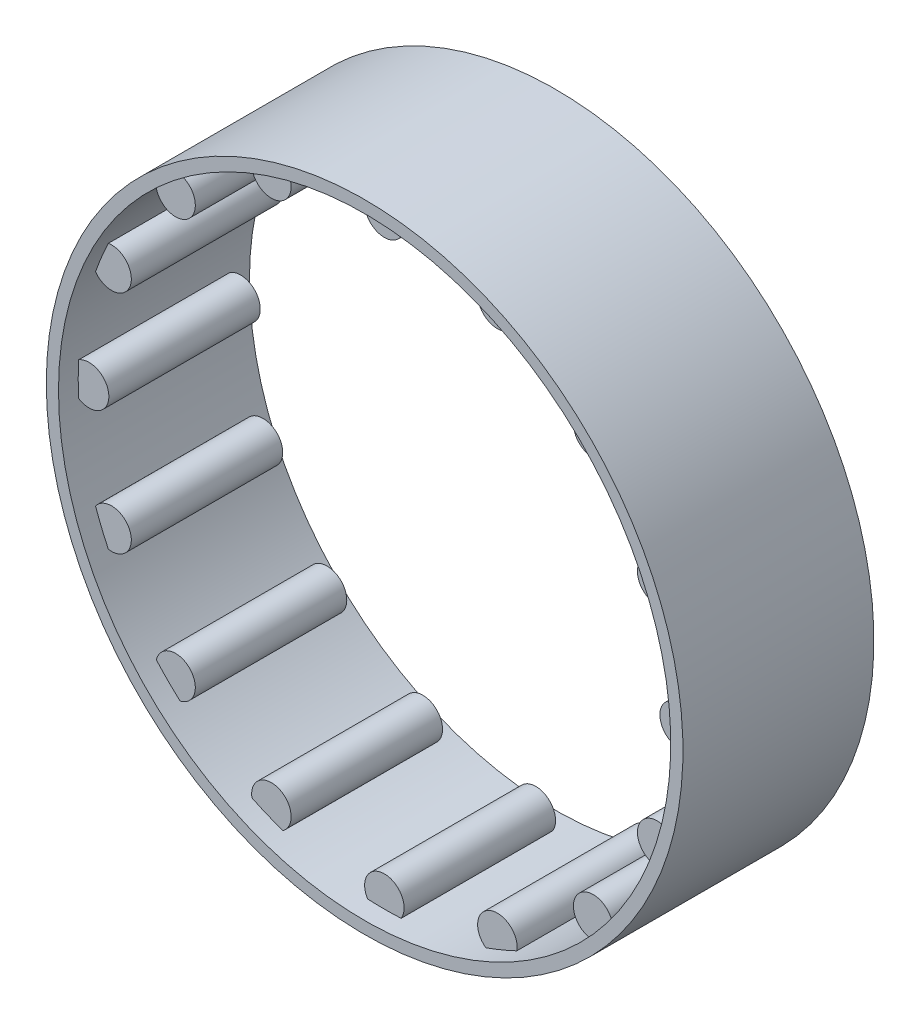
from build123d import *

# Parameters (mm, degrees)
SKETCH1_R              = 3
BOSS_EXTRUDE2_DEPTH    = 29
BOSS_EXTRUDE2_2_DEPTH  = 29
BOSS_EXTRUDE2_3_DEPTH  = 29
BOSS_EXTRUDE2_4_DEPTH  = 29
BOSS_EXTRUDE2_5_DEPTH  = 29
BOSS_EXTRUDE2_6_DEPTH  = 29
BOSS_EXTRUDE2_7_DEPTH  = 29
BOSS_EXTRUDE2_8_DEPTH  = 29
BOSS_EXTRUDE2_9_DEPTH  = 29
BOSS_EXTRUDE2_10_DEPTH = 29
BOSS_EXTRUDE2_11_DEPTH = 29
BOSS_EXTRUDE2_12_DEPTH = 29
BOSS_EXTRUDE2_13_DEPTH = 29
BOSS_EXTRUDE2_14_DEPTH = 29
BOSS_EXTRUDE2_15_DEPTH = 29
BOSS_EXTRUDE2_16_DEPTH = 29
SKETCH2_R              = 47.85
SKETCH2_R_2            = 46.5
BOSS_EXTRUDE4_DEPTH    = 29
SKETCH3_R              = 46.5
CUT_EXTRUDE1_DEPTH     = 3
SKETCH4_R              = 46.5
CUT_EXTRUDE2_DEPTH     = 3
SKETCH5_R              = 48.35
SKETCH5_R_2            = 47.85
BOSS_EXTRUDE6_DEPTH    = 29


with BuildPart() as part:
    # Sketch1 → Boss-Extrude2 (new body)
    with BuildSketch(Plane.XY):
        with Locations((-41.435997033, 17.163351942)):
            Circle(SKETCH1_R)
    extrude(amount=BOSS_EXTRUDE2_DEPTH)


with BuildPart() as body_2:
    # Sketch1 → Boss-Extrude2 2 (new body)
    with BuildSketch(Plane.XY):
        with Locations((-31.713739136, 31.713739136)):
            Circle(SKETCH1_R)
    extrude(amount=BOSS_EXTRUDE2_2_DEPTH)


with BuildPart() as body_3:
    # Sketch1 → Boss-Extrude2 3 (new body)
    with BuildSketch(Plane.XY):
        with Locations((-17.163351942, 41.435997033)):
            Circle(SKETCH1_R)
    extrude(amount=BOSS_EXTRUDE2_3_DEPTH)


with BuildPart() as body_4:
    # Sketch1 → Boss-Extrude2 4 (new body)
    with BuildSketch(Plane.XY):
        with Locations((0, 44.85)):
            Circle(SKETCH1_R)
    extrude(amount=BOSS_EXTRUDE2_4_DEPTH)


with BuildPart() as body_5:
    # Sketch1 → Boss-Extrude2 5 (new body)
    with BuildSketch(Plane.XY):
        with Locations((17.163351942, 41.435997033)):
            Circle(SKETCH1_R)
    extrude(amount=BOSS_EXTRUDE2_5_DEPTH)


with BuildPart() as body_6:
    # Sketch1 → Boss-Extrude2 6 (new body)
    with BuildSketch(Plane.XY):
        with Locations((31.713739136, 31.713739136)):
            Circle(SKETCH1_R)
    extrude(amount=BOSS_EXTRUDE2_6_DEPTH)


with BuildPart() as body_7:
    # Sketch1 → Boss-Extrude2 7 (new body)
    with BuildSketch(Plane.XY):
        with Locations((41.435997033, 17.163351942)):
            Circle(SKETCH1_R)
    extrude(amount=BOSS_EXTRUDE2_7_DEPTH)


with BuildPart() as body_8:
    # Sketch1 → Boss-Extrude2 8 (new body)
    with BuildSketch(Plane.XY):
        with Locations((44.85, 0)):
            Circle(SKETCH1_R)
    extrude(amount=BOSS_EXTRUDE2_8_DEPTH)


with BuildPart() as body_9:
    # Sketch1 → Boss-Extrude2 9 (new body)
    with BuildSketch(Plane.XY):
        with Locations((41.435997033, -17.163351942)):
            Circle(SKETCH1_R)
    extrude(amount=BOSS_EXTRUDE2_9_DEPTH)


with BuildPart() as body_10:
    # Sketch1 → Boss-Extrude2 10 (new body)
    with BuildSketch(Plane.XY):
        with Locations((17.163351942, -41.435997033)):
            Circle(SKETCH1_R)
    extrude(amount=BOSS_EXTRUDE2_10_DEPTH)


with BuildPart() as body_11:
    # Sketch1 → Boss-Extrude2 11 (new body)
    with BuildSketch(Plane.XY):
        with Locations((0, -44.85)):
            Circle(SKETCH1_R)
    extrude(amount=BOSS_EXTRUDE2_11_DEPTH)


with BuildPart() as body_12:
    # Sketch1 → Boss-Extrude2 12 (new body)
    with BuildSketch(Plane.XY):
        with Locations((-17.163351942, -41.435997033)):
            Circle(SKETCH1_R)
    extrude(amount=BOSS_EXTRUDE2_12_DEPTH)


with BuildPart() as body_13:
    # Sketch1 → Boss-Extrude2 13 (new body)
    with BuildSketch(Plane.XY):
        with Locations((-41.435997033, -17.163351942)):
            Circle(SKETCH1_R)
    extrude(amount=BOSS_EXTRUDE2_13_DEPTH)


with BuildPart() as body_14:
    # Sketch1 → Boss-Extrude2 14 (new body)
    with BuildSketch(Plane.XY):
        with Locations((-31.713739136, -31.713739136)):
            Circle(SKETCH1_R)
    extrude(amount=BOSS_EXTRUDE2_14_DEPTH)


with BuildPart() as body_15:
    # Sketch1 → Boss-Extrude2 15 (new body)
    with BuildSketch(Plane.XY):
        with Locations((-44.85, 0)):
            Circle(SKETCH1_R)
    extrude(amount=BOSS_EXTRUDE2_15_DEPTH)


with BuildPart() as body_16:
    # Sketch1 → Boss-Extrude2 16 (new body)
    with BuildSketch(Plane.XY):
        with Locations((31.713739136, -31.713739136)):
            Circle(SKETCH1_R)
    extrude(amount=BOSS_EXTRUDE2_16_DEPTH)


with BuildPart() as body_17:
    # Sketch2 → Boss-Extrude4 (new body)
    with BuildSketch(Plane(origin=(0, 0, 0), x_dir=(-1, 0, 0), z_dir=(0, 0, -1))):
        Circle(SKETCH2_R)
        Circle(SKETCH2_R_2, mode=Mode.SUBTRACT)
    extrude(amount=-BOSS_EXTRUDE4_DEPTH)


with BuildPart() as cut_extrude1_tool:
    # Sketch3 → Cut-Extrude1 (new body)
    with BuildSketch(Plane(origin=(0, 0, 0), x_dir=(-1, 0, 0), z_dir=(0, 0, -1))):
        Circle(SKETCH3_R)
    extrude(amount=-CUT_EXTRUDE1_DEPTH)


with BuildPart() as part_1:
    add(part.part)

    # Cut-Extrude1: cut by cut_extrude1_tool
    add(cut_extrude1_tool.part, mode=Mode.SUBTRACT)


with BuildPart() as body_2_1:
    add(body_2.part)

    # Cut-Extrude1: cut by cut_extrude1_tool
    add(cut_extrude1_tool.part, mode=Mode.SUBTRACT)


with BuildPart() as body_3_1:
    add(body_3.part)

    # Cut-Extrude1: cut by cut_extrude1_tool
    add(cut_extrude1_tool.part, mode=Mode.SUBTRACT)


with BuildPart() as body_4_1:
    add(body_4.part)

    # Cut-Extrude1: cut by cut_extrude1_tool
    add(cut_extrude1_tool.part, mode=Mode.SUBTRACT)


with BuildPart() as body_5_1:
    add(body_5.part)

    # Cut-Extrude1: cut by cut_extrude1_tool
    add(cut_extrude1_tool.part, mode=Mode.SUBTRACT)


with BuildPart() as body_6_1:
    add(body_6.part)

    # Cut-Extrude1: cut by cut_extrude1_tool
    add(cut_extrude1_tool.part, mode=Mode.SUBTRACT)


with BuildPart() as body_7_1:
    add(body_7.part)

    # Cut-Extrude1: cut by cut_extrude1_tool
    add(cut_extrude1_tool.part, mode=Mode.SUBTRACT)


with BuildPart() as body_8_1:
    add(body_8.part)

    # Cut-Extrude1: cut by cut_extrude1_tool
    add(cut_extrude1_tool.part, mode=Mode.SUBTRACT)


with BuildPart() as body_9_1:
    add(body_9.part)

    # Cut-Extrude1: cut by cut_extrude1_tool
    add(cut_extrude1_tool.part, mode=Mode.SUBTRACT)


with BuildPart() as body_10_1:
    add(body_10.part)

    # Cut-Extrude1: cut by cut_extrude1_tool
    add(cut_extrude1_tool.part, mode=Mode.SUBTRACT)


with BuildPart() as body_11_1:
    add(body_11.part)

    # Cut-Extrude1: cut by cut_extrude1_tool
    add(cut_extrude1_tool.part, mode=Mode.SUBTRACT)


with BuildPart() as body_12_1:
    add(body_12.part)

    # Cut-Extrude1: cut by cut_extrude1_tool
    add(cut_extrude1_tool.part, mode=Mode.SUBTRACT)


with BuildPart() as body_13_1:
    add(body_13.part)

    # Cut-Extrude1: cut by cut_extrude1_tool
    add(cut_extrude1_tool.part, mode=Mode.SUBTRACT)


with BuildPart() as body_14_1:
    add(body_14.part)

    # Cut-Extrude1: cut by cut_extrude1_tool
    add(cut_extrude1_tool.part, mode=Mode.SUBTRACT)


with BuildPart() as body_15_1:
    add(body_15.part)

    # Cut-Extrude1: cut by cut_extrude1_tool
    add(cut_extrude1_tool.part, mode=Mode.SUBTRACT)


with BuildPart() as body_16_1:
    add(body_16.part)

    # Cut-Extrude1: cut by cut_extrude1_tool
    add(cut_extrude1_tool.part, mode=Mode.SUBTRACT)


with BuildPart() as cut_extrude2_tool:
    # Sketch4 → Cut-Extrude2 (new body)
    with BuildSketch(Plane.XY.offset(29)):
        Circle(SKETCH4_R)
    extrude(amount=-CUT_EXTRUDE2_DEPTH)


with BuildPart() as part_2:
    add(part_1.part)

    # Cut-Extrude2: cut by cut_extrude2_tool
    add(cut_extrude2_tool.part, mode=Mode.SUBTRACT)



with BuildPart() as body_2_2:
    add(body_2_1.part)

    # Cut-Extrude2: cut by cut_extrude2_tool
    add(cut_extrude2_tool.part, mode=Mode.SUBTRACT)


with BuildPart() as body_3_2:
    add(body_3_1.part)

    # Cut-Extrude2: cut by cut_extrude2_tool
    add(cut_extrude2_tool.part, mode=Mode.SUBTRACT)


with BuildPart() as body_4_2:
    add(body_4_1.part)

    # Cut-Extrude2: cut by cut_extrude2_tool
    add(cut_extrude2_tool.part, mode=Mode.SUBTRACT)


with BuildPart() as body_5_2:
    add(body_5_1.part)

    # Cut-Extrude2: cut by cut_extrude2_tool
    add(cut_extrude2_tool.part, mode=Mode.SUBTRACT)


with BuildPart() as body_6_2:
    add(body_6_1.part)

    # Cut-Extrude2: cut by cut_extrude2_tool
    add(cut_extrude2_tool.part, mode=Mode.SUBTRACT)


with BuildPart() as body_7_2:
    add(body_7_1.part)

    # Cut-Extrude2: cut by cut_extrude2_tool
    add(cut_extrude2_tool.part, mode=Mode.SUBTRACT)


with BuildPart() as body_8_2:
    add(body_8_1.part)

    # Cut-Extrude2: cut by cut_extrude2_tool
    add(cut_extrude2_tool.part, mode=Mode.SUBTRACT)


with BuildPart() as body_9_2:
    add(body_9_1.part)

    # Cut-Extrude2: cut by cut_extrude2_tool
    add(cut_extrude2_tool.part, mode=Mode.SUBTRACT)


with BuildPart() as body_10_2:
    add(body_10_1.part)

    # Cut-Extrude2: cut by cut_extrude2_tool
    add(cut_extrude2_tool.part, mode=Mode.SUBTRACT)


with BuildPart() as body_11_2:
    add(body_11_1.part)

    # Cut-Extrude2: cut by cut_extrude2_tool
    add(cut_extrude2_tool.part, mode=Mode.SUBTRACT)


with BuildPart() as body_12_2:
    add(body_12_1.part)

    # Cut-Extrude2: cut by cut_extrude2_tool
    add(cut_extrude2_tool.part, mode=Mode.SUBTRACT)


with BuildPart() as body_13_2:
    add(body_13_1.part)

    # Cut-Extrude2: cut by cut_extrude2_tool
    add(cut_extrude2_tool.part, mode=Mode.SUBTRACT)


with BuildPart() as body_14_2:
    add(body_14_1.part)

    # Cut-Extrude2: cut by cut_extrude2_tool
    add(cut_extrude2_tool.part, mode=Mode.SUBTRACT)


with BuildPart() as body_15_2:
    add(body_15_1.part)

    # Cut-Extrude2: cut by cut_extrude2_tool
    add(cut_extrude2_tool.part, mode=Mode.SUBTRACT)


with BuildPart() as body_16_2:
    add(body_16_1.part)

    # Cut-Extrude2: cut by cut_extrude2_tool
    add(cut_extrude2_tool.part, mode=Mode.SUBTRACT)


with BuildPart() as part_3:
    add(part_2.part)

    add(body_2_2.part)  # Boss-Extrude6 merges body 2

    add(body_3_2.part)  # Boss-Extrude6 merges body 3

    add(body_4_2.part)  # Boss-Extrude6 merges body 4

    add(body_5_2.part)  # Boss-Extrude6 merges body 5

    add(body_6_2.part)  # Boss-Extrude6 merges body 6

    add(body_7_2.part)  # Boss-Extrude6 merges body 7

    add(body_8_2.part)  # Boss-Extrude6 merges body 8

    add(body_9_2.part)  # Boss-Extrude6 merges body 9

    add(body_10_2.part)  # Boss-Extrude6 merges body 10

    add(body_11_2.part)  # Boss-Extrude6 merges body 11

    add(body_12_2.part)  # Boss-Extrude6 merges body 12

    add(body_13_2.part)  # Boss-Extrude6 merges body 13

    add(body_14_2.part)  # Boss-Extrude6 merges body 14

    add(body_15_2.part)  # Boss-Extrude6 merges body 15

    add(body_16_2.part)  # Boss-Extrude6 merges body 16

    add(body_17.part)  # Boss-Extrude6 merges body 17
    # Sketch5 → Boss-Extrude6 (add)
    with BuildSketch(Plane(origin=(0, 0, 0), x_dir=(-1, 0, 0), z_dir=(0, 0, -1))):
        Circle(SKETCH5_R)
        Circle(SKETCH5_R_2, mode=Mode.SUBTRACT)
    extrude(amount=-BOSS_EXTRUDE6_DEPTH)


solid = part_3.part
